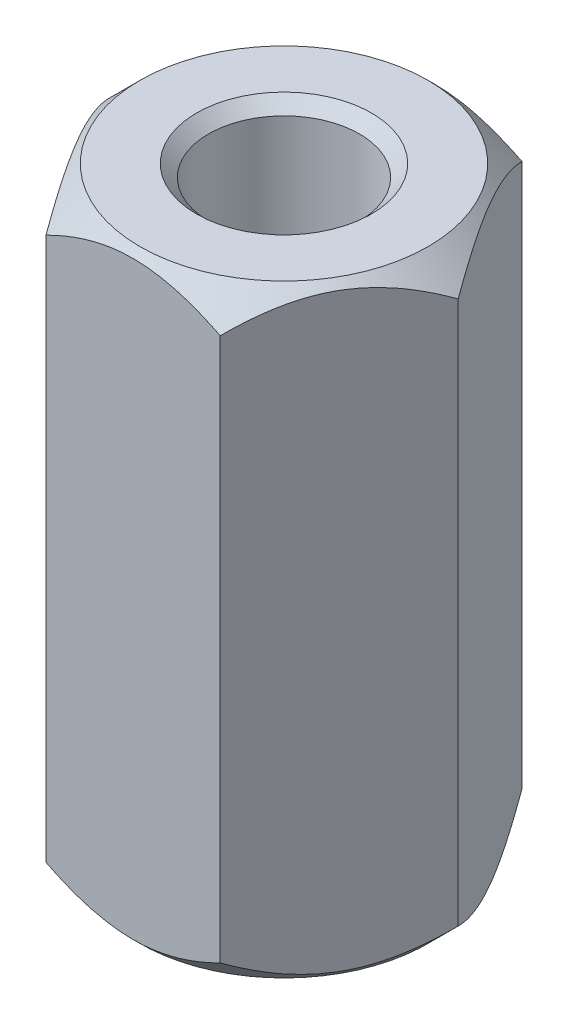
from build123d import *

# Parameters (mm, degrees)
SKETCH1_R           = 1.25
BOSS_EXTRUDE1_DEPTH = 10
CHAMFER1_SIZE       = 0.2


with BuildPart() as part:
    # Sketch1 → Boss-Extrude1 (new body)
    with BuildSketch(Plane(origin=(0, 0, 0), x_dir=(1, 0, 0), z_dir=(0, 1, 0))):
        Polygon((1.443375673, 2.5), (-1.443375673, 2.5), (-2.886751346, 0), (-1.443375673, -2.5), (1.443375673, -2.5), (2.886751346, 0), align=None)
        with Locations(Location((0, 0, 0), (0, 0, 270))):  # turned: the seam where the file's is
            Circle(SKETCH1_R, mode=Mode.SUBTRACT)
    extrude(amount=BOSS_EXTRUDE1_DEPTH)

    # Chamfer1
    chamfer1_edges = [part.edges().sort_by_distance(p)[0] for p in [
        (0, 0, -1.25),
        (0, 10, -1.25),
    ]]
    chamfer(chamfer1_edges, length=CHAMFER1_SIZE)

    # Sketch2 → Cut-Revolve1 (revolve, cut)
    with BuildSketch(Plane.XY, mode=Mode.PRIVATE) as cut_revolve1_sk:
        Polygon((2.386751346, 10), (2.886751346, 9.5), (2.886751346, 10), align=None)
        Polygon((2.386751346, 0), (2.886751346, 0), (2.886751346, 0.5), align=None)
    revolve(cut_revolve1_sk.sketch.rotate(Axis((0, 0, 0), (0, 1, 0)), 270), axis=Axis((0, 0, 0), (0, 1, 0)), mode=Mode.SUBTRACT)  # turned: the seam where the file's is


solid = part.part
